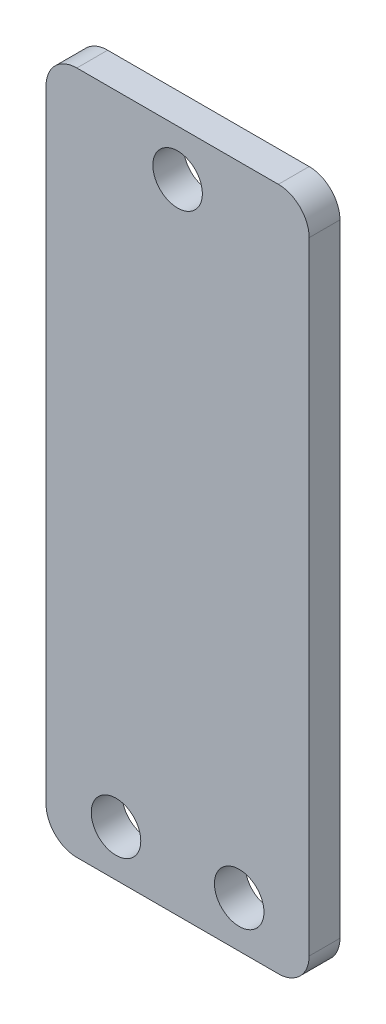
from build123d import *

# Parameters (mm, degrees)
BOSS_EXTRUDE1_DEPTH    = 3.175
F_10_CLEARANCE_HOLE1_D = 5.1054


with BuildPart() as part:
    # Sketch1 → Boss-Extrude1 (new body)
    with BuildSketch(Plane.XY):
        with BuildLine():
            Line((10.3886, -4.6609), (-10.3886, -4.6609))
            ThreePointArc((-10.3886, -4.6609), (-12.63366403, -3.73096403), (-13.5636, -1.4859))
            Line((-13.5636, -1.4859), (-13.5636, 62.6618))
            ThreePointArc((-13.5636, 62.6618), (-12.63366403, 64.90686403), (-10.3886, 65.8368))
            Line((-10.3886, 65.8368), (10.3886, 65.8368))
            ThreePointArc((10.3886, 65.8368), (12.63366403, 64.90686403), (13.5636, 62.6618))
            Line((13.5636, 62.6618), (13.5636, -1.4859))
            ThreePointArc((13.5636, -1.4859), (12.63366403, -3.73096403), (10.3886, -4.6609))
        make_face()
    extrude(amount=BOSS_EXTRUDE1_DEPTH)

    # #10 Clearance Hole1 (through all)
    with Locations(Plane.XY.offset(3.175)):
        with Locations((6.35, 0.1016), (-6.35, 0.1016), (0, 61.0743)):
            Hole(F_10_CLEARANCE_HOLE1_D / 2)


solid = part.part
